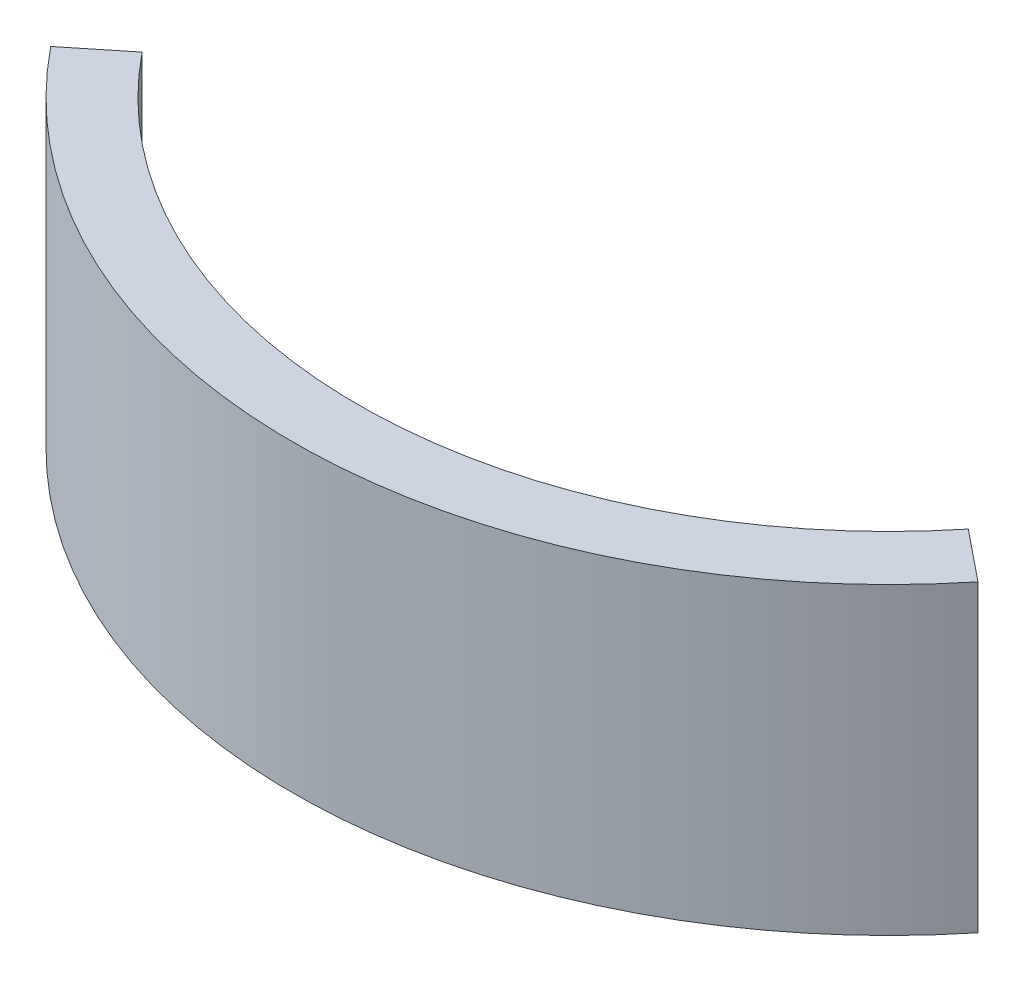
from build123d import *

# Parameters (mm, degrees)
BOSS_EXTRUDE1_DEPTH = 6.08


with BuildPart() as part:
    # Sketch1 → Boss-Extrude1 (new body)
    with BuildSketch(Plane(origin=(0, 0, 0), x_dir=(1, 0, 0), z_dir=(0, 1, 0))):
        with BuildLine():
            Line((9.274044896, 4.431442644), (8.262613825, 5.248147725))
            ThreePointArc((8.262613825, 5.248147725), (0, 1.3), (-8.262613825, 5.248147725))
            Line((-8.262613825, 5.248147725), (-9.274044896, 4.431442644))
            ThreePointArc((-9.274044896, 4.431442644), (0, 0), (9.274044896, 4.431442644))
        make_face()
    extrude(amount=BOSS_EXTRUDE1_DEPTH)


solid = part.part
